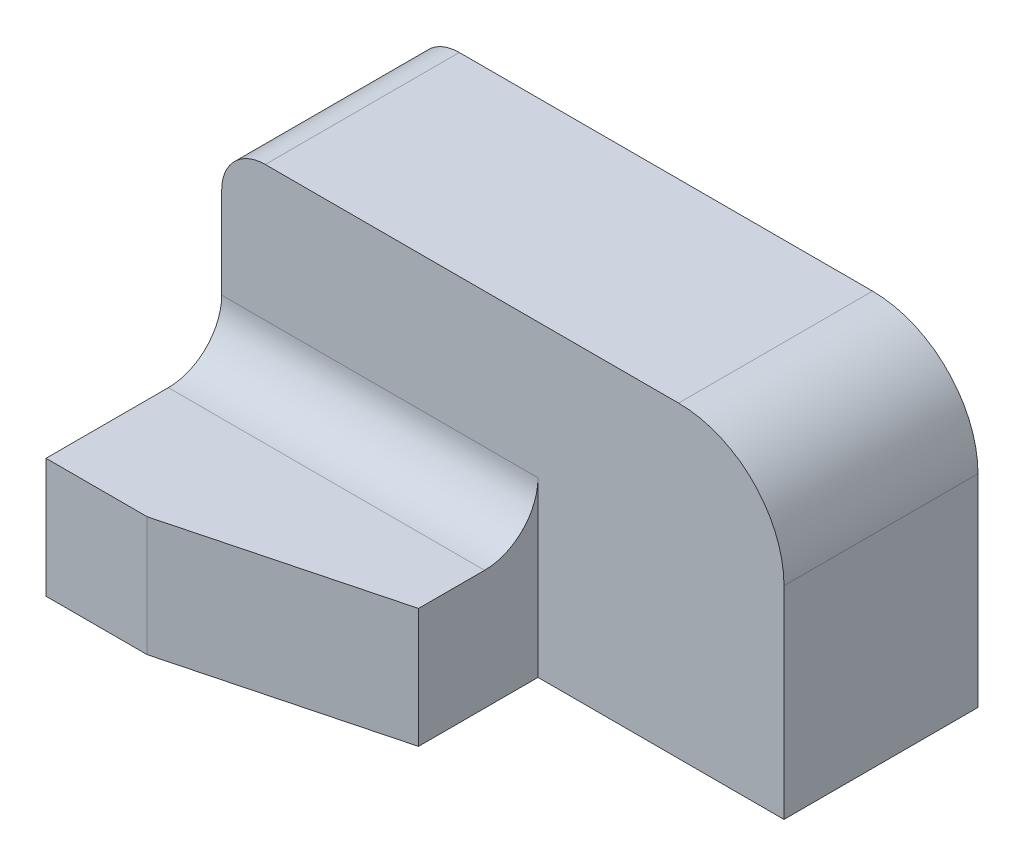
from build123d import *

# Parameters (mm, degrees)
BOSS_EXTRUDE1_DEPTH = 35.052
SKETCH1_4_W         = 57.15
SKETCH1_4_H         = 21.59
BOSS_EXTRUDE2_DEPTH = 66.802
FILLET1_R           = 9.652
CUT_EXTRUDE1_DEPTH  = 127.267638372


with BuildPart() as part:
    # Sketch1 → Boss-Extrude1 (new body)
    with BuildSketch(Plane.XY):
        with BuildLine():
            Line((0, 0), (0, 36.576))
            ThreePointArc((0, 36.576), (-5.579615818, 50.046384182), (-19.05, 55.626))
            Line((-19.05, 55.626), (-93.726, 55.626))
            ThreePointArc((-93.726, 55.626), (-99.293758795, 53.319758795), (-101.6, 47.752))
            Line((-101.6, 47.752), (-101.6, 0))
            Line((-101.6, 0), (0, 0))
        make_face()
    extrude(amount=BOSS_EXTRUDE1_DEPTH)

    # Sketch1_4 → Boss-Extrude2 (add)
    with BuildSketch(Plane.XY):
        with Locations((-73.025, 10.795)):
            Rectangle(SKETCH1_4_W, SKETCH1_4_H)
    extrude(amount=BOSS_EXTRUDE2_DEPTH)

    # Fillet1
    fillet1_edges = [part.edges().sort_by_distance(p)[0] for p in [
        (-73.025, 21.59, 35.052),
    ]]
    fillet(fillet1_edges, radius=FILLET1_R)

    # Sketch3 → Cut-Extrude1 (cut, through all)
    with BuildSketch(Plane(origin=(0, 21.59, 0), x_dir=(1, 0, 0), z_dir=(0, 1, 0))):
        Polygon((-83.312, -66.802), (-44.45, -56.642), (-44.45, -66.802), align=None)
    extrude(amount=-CUT_EXTRUDE1_DEPTH, mode=Mode.SUBTRACT)


solid = part.part
